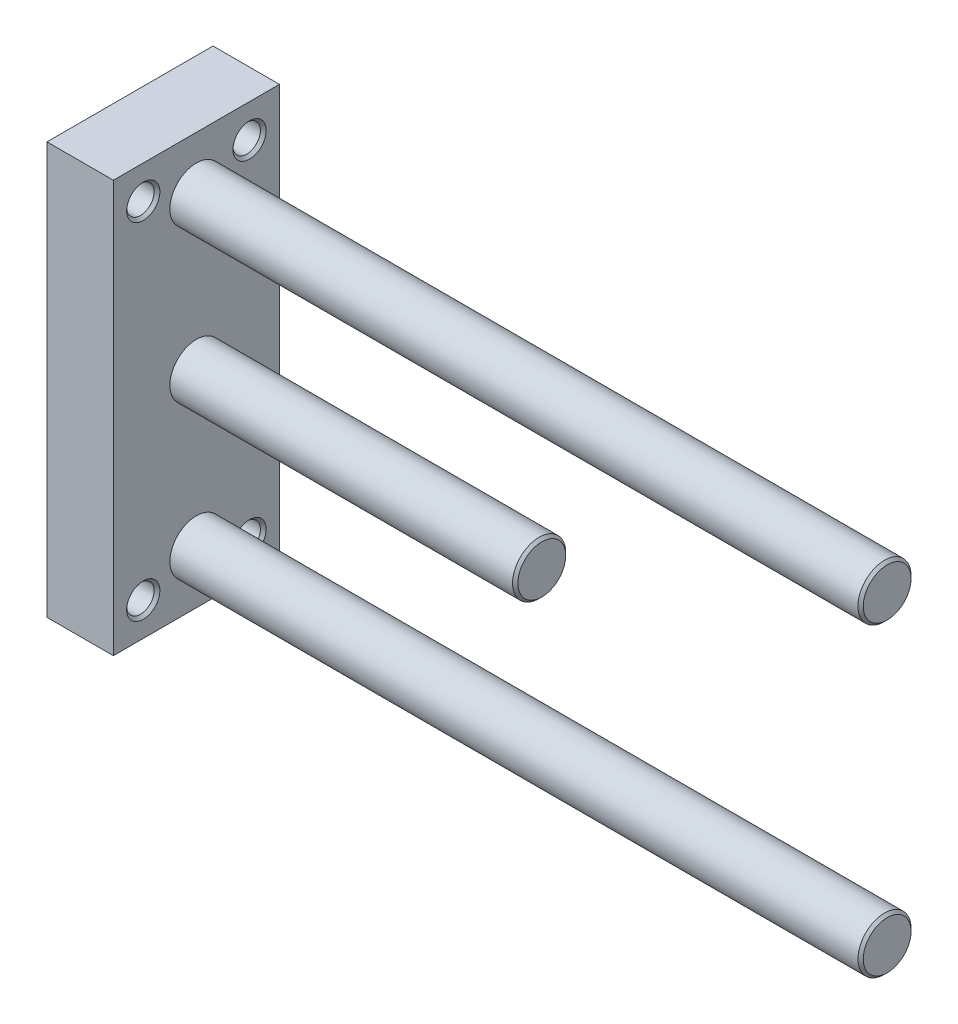
from build123d import *

# Parameters (mm, degrees)
SKETCH1_W           = 25
SKETCH1_H           = 62
BOSS_EXTRUDE1_DEPTH = 10


with BuildPart() as part:
    # Sketch1 → Boss-Extrude1 (new body)
    with BuildSketch(Plane(origin=(0, 0, 0), x_dir=(0, 0, -1), z_dir=(1, 0, 0))):
        Rectangle(SKETCH1_W, SKETCH1_H)
    extrude(amount=BOSS_EXTRUDE1_DEPTH)

    # Sketch2 → Cut-Revolve1 (revolve, cut)
    with BuildSketch(Plane(origin=(0, 26, 0), x_dir=(-1, 0, 0), z_dir=(0, 1, 0))):
        Polygon((0, -8), (0, -10.5), (-0.433, -10.067), (-9.567, -10.067), (-10, -10.5), (-10, -8), align=None)
    revolve(axis=Axis((10, 26, -8), (-1, 0, 0)), mode=Mode.SUBTRACT)

    # Sketch3 → Cut-Revolve2 (revolve, cut)
    with BuildSketch(Plane(origin=(0, -26, 0), x_dir=(-1, 0, 0), z_dir=(0, 1, 0))):
        Polygon((0, -8), (0, -10.5), (-0.433, -10.067), (-9.567, -10.067), (-10, -10.5), (-10, -8), align=None)
    revolve(axis=Axis((10, -26, -8), (-1, 0, 0)), mode=Mode.SUBTRACT)

    # Sketch4 → Cut-Revolve3 (revolve, cut)
    with BuildSketch(Plane(origin=(0, -26, 0), x_dir=(-1, 0, 0), z_dir=(0, 1, 0))):
        Polygon((0, 8), (0, 5.5), (-0.433, 5.933), (-9.567, 5.933), (-10, 5.5), (-10, 8), align=None)
    revolve(axis=Axis((10, -26, 8), (-1, 0, 0)), mode=Mode.SUBTRACT)

    # Sketch5 → Cut-Revolve4 (revolve, cut)
    with BuildSketch(Plane(origin=(0, 26, 0), x_dir=(-1, 0, 0), z_dir=(0, 1, 0))):
        Polygon((0, 8), (0, 5.5), (-0.433, 5.933), (-9.567, 5.933), (-10, 5.5), (-10, 8), align=None)
    revolve(axis=Axis((10, 26, 8), (-1, 0, 0)), mode=Mode.SUBTRACT)

    # Sketch6 → Cut-Revolve5 (revolve, cut)
    with BuildSketch(Plane(origin=(0, 23, 0), x_dir=(-1, 0, 0), z_dir=(0, 1, 0))):
        Polygon((0, 0), (0, -3.8), (-5.555555556, -3.8), (-5.555555556, -3.5), (-2.055555556, -3.5), (-1.555555556, -3), (-1.555555556, -1.5), (-4.155555556, -1.5), (-5.021580959, 0), align=None)
    revolve(axis=Axis((5.021580959, 23, 0), (-1, 0, 0)), mode=Mode.SUBTRACT)

    # Sketch7 → Cut-Revolve6 (revolve, cut)
    with BuildSketch(Plane(origin=(0, 0, 0), x_dir=(-1, 0, 0), z_dir=(0, 1, 0))):
        Polygon((0, 0), (0, -3.8), (-5.555555556, -3.8), (-5.555555556, -3.5), (-2.055555556, -3.5), (-1.555555556, -3), (-1.555555556, -1.5), (-4.155555556, -1.5), (-5.021580959, 0), align=None)
    revolve(axis=Axis((5.021580959, 0, 0), (-1, 0, 0)), mode=Mode.SUBTRACT)

    # Sketch8 → Cut-Revolve7 (revolve, cut)
    with BuildSketch(Plane(origin=(0, -23, 0), x_dir=(-1, 0, 0), z_dir=(0, 1, 0))):
        Polygon((0, 0), (0, -3.8), (-5.555555556, -3.8), (-5.555555556, -3.5), (-2.055555556, -3.5), (-1.555555556, -3), (-1.555555556, -1.5), (-4.155555556, -1.5), (-5.021580959, 0), align=None)
    revolve(axis=Axis((5.021580959, -23, 0), (-1, 0, 0)), mode=Mode.SUBTRACT)

    # Sketch9 → Revolve1 (revolve)
    with BuildSketch(Plane(origin=(0, 0, 0), x_dir=(-1, 0, 0), z_dir=(0, 1, 0))):
        Polygon((-10, 0), (-10, -4), (-61.6, -4), (-62, -3.6), (-62, 0), align=None)
    revolve(axis=Axis((62, 0, 0), (-1, 0, 0)))

    # Sketch10 → Revolve2 (revolve)
    with BuildSketch(Plane(origin=(0, -23, 0), x_dir=(-1, 0, 0), z_dir=(0, 1, 0))):
        Polygon((-10, 0), (-10, -4), (-113.6, -4), (-114, -3.6), (-114, 0), align=None)
    revolve(axis=Axis((114, -23, 0), (-1, 0, 0)))

    # Sketch11 → Revolve3 (revolve)
    with BuildSketch(Plane(origin=(0, 23, 0), x_dir=(-1, 0, 0), z_dir=(0, 1, 0))):
        Polygon((-10, 0), (-10, -4), (-113.6, -4), (-114, -3.6), (-114, 0), align=None)
    revolve(axis=Axis((114, 23, 0), (-1, 0, 0)))


solid = part.part
